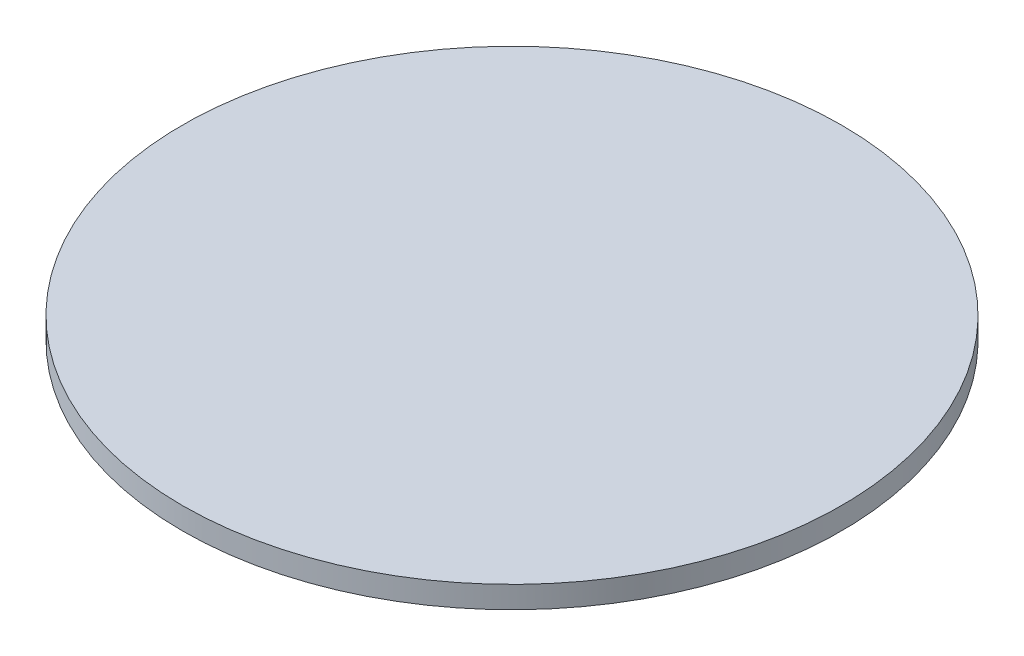
from build123d import *

# Parameters (mm, degrees)
SKETCH1_R           = 38.1
BOSS_EXTRUDE1_DEPTH = 2.54


with BuildPart() as part:
    # Sketch1 → Boss-Extrude1 (new body)
    with BuildSketch(Plane(origin=(0, 0, 0), x_dir=(1, 0, 0), z_dir=(0, 1, 0))):
        Circle(SKETCH1_R)
    extrude(amount=BOSS_EXTRUDE1_DEPTH)


solid = part.part
